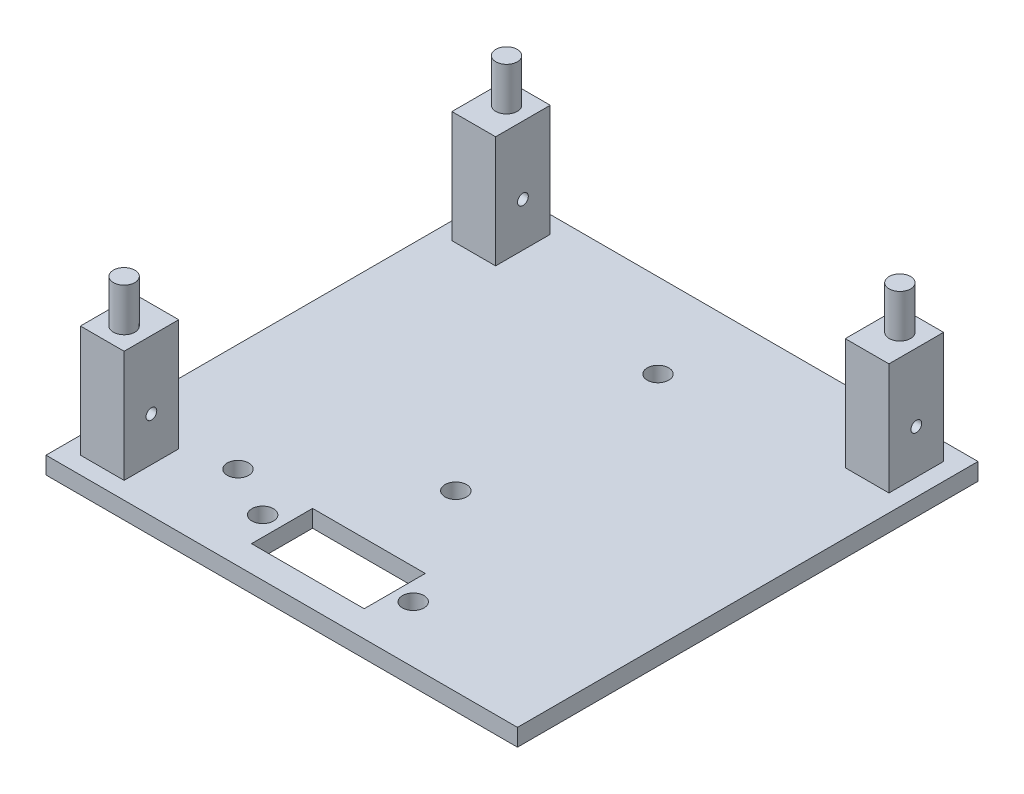
from build123d import *

# Parameters (mm, degrees)
SKETCH2_W           = 54.8
SKETCH2_H           = 53.53
BOSS_EXTRUDE1_DEPTH = 2
SKETCH3_W           = 5.08
SKETCH3_H           = 6.35
BOSS_EXTRUDE2_DEPTH = 13
SKETCH6_R           = 1.25
BOSS_EXTRUDE3_DEPTH = 5
CUT_EXTRUDE1_REACH  = 22
SKETCH7_W           = 13.1
SKETCH7_H           = 7.1
CUT_EXTRUDE2_REACH  = 22
SKETCH8_R           = 1.25
CUT_EXTRUDE4_REACH  = 54.8
SKETCH9_R           = 0.625
CUT_EXTRUDE5_REACH  = 54.8
SKETCH10_R          = 0.625
CUT_EXTRUDE6_REACH  = 54.8
SKETCH11_R          = 0.625
CUT_EXTRUDE7_REACH  = 4
SKETCH12_R          = 1.25
CUT_EXTRUDE8_REACH  = 4
SKETCH13_R          = 1.25


with BuildPart() as part:
    # Sketch2 → Boss-Extrude1 (new body)
    with BuildSketch(Plane(origin=(0, 0, 0), x_dir=(1, 0, 0), z_dir=(0, 1, 0))):
        Rectangle(SKETCH2_W, SKETCH2_H)
    extrude(amount=BOSS_EXTRUDE1_DEPTH)

    # Sketch3 → Boss-Extrude2 (add)
    with BuildSketch(Plane(origin=(0, 2, 0), x_dir=(1, 0, 0), z_dir=(0, 1, 0))):
        with Locations((-22.86, 21.59)):
            Rectangle(SKETCH3_W, SKETCH3_H)
        with Locations((22.86, 21.59)):
            Rectangle(SKETCH3_W, SKETCH3_H)
        with Locations((-22.86, -21.59)):
            Rectangle(SKETCH3_W, SKETCH3_H)
    extrude(amount=BOSS_EXTRUDE2_DEPTH)

    # Sketch6 → Boss-Extrude3 (add)
    with BuildSketch(Plane(origin=(0, 15, 0), x_dir=(1, 0, 0), z_dir=(0, 1, 0))):
        with Locations((-22.86, 22.225)):
            Circle(SKETCH6_R)
        with Locations((22.86, 22.225)):
            Circle(SKETCH6_R)
        with Locations((-22.86, -22.225)):
            Circle(SKETCH6_R)
    extrude(amount=BOSS_EXTRUDE3_DEPTH)

    # Sketch7 → Cut-Extrude1 (cut, up to next)
    with BuildSketch(Plane(origin=(0, 0, 0), x_dir=(-1, 0, 0), z_dir=(0, -1, 0)), mode=Mode.PRIVATE) as cut_extrude1_sk1:
        with Locations((0, -20.180596319)):
            Rectangle(SKETCH7_W, SKETCH7_H)
    cut_extrude1_tool1 = extrude(cut_extrude1_sk1.sketch, amount=-CUT_EXTRUDE1_REACH, mode=Mode.PRIVATE) & part.part
    add(cut_extrude1_tool1.solids().sort_by_distance((0, 0, 20.180596))[0], mode=Mode.SUBTRACT)

    # Sketch8 → Cut-Extrude2 (cut, up to next)
    with BuildSketch(Plane.XZ, mode=Mode.PRIVATE) as cut_extrude2_sk1:
        with Locations((0, 6.530805807)):
            Circle(SKETCH8_R)
    cut_extrude2_tool1 = extrude(cut_extrude2_sk1.sketch, amount=-CUT_EXTRUDE2_REACH, mode=Mode.PRIVATE) & part.part
    add(cut_extrude2_tool1.solids().sort_by_distance((0, 0, 6.530806))[0], mode=Mode.SUBTRACT)
    # Sketch8 → Cut-Extrude2 (cut, up to next)
    with BuildSketch(Plane.XZ, mode=Mode.PRIVATE) as cut_extrude2_sk2:
        with Locations((0, -16.969194193)):
            Circle(SKETCH8_R)
    cut_extrude2_tool2 = extrude(cut_extrude2_sk2.sketch, amount=-CUT_EXTRUDE2_REACH, mode=Mode.PRIVATE) & part.part
    add(cut_extrude2_tool2.solids().sort_by_distance((0, 0, -16.969194))[0], mode=Mode.SUBTRACT)

    # Sketch9 → Cut-Extrude4 (cut, up to next)
    with BuildSketch(Plane.ZY.offset(25.4), mode=Mode.PRIVATE) as cut_extrude4_sk1:
        with Locations((-21.59, 7.11470595)):
            Circle(SKETCH9_R)
    cut_extrude4_tool1 = extrude(cut_extrude4_sk1.sketch, amount=-CUT_EXTRUDE4_REACH, mode=Mode.PRIVATE) & part.part
    add(cut_extrude4_tool1.solids().sort_by_distance((-25.4, 7.114706, -21.59))[0], mode=Mode.SUBTRACT)

    # Sketch10 → Cut-Extrude5 (cut, up to next)
    with BuildSketch(Plane(origin=(25.4, 0, 0), x_dir=(0, 0, -1), z_dir=(1, 0, 0)), mode=Mode.PRIVATE) as cut_extrude5_sk1:
        with Locations((21.595, 7.11)):
            Circle(SKETCH10_R)
    cut_extrude5_tool1 = extrude(cut_extrude5_sk1.sketch, amount=-CUT_EXTRUDE5_REACH, mode=Mode.PRIVATE) & part.part
    add(cut_extrude5_tool1.solids().sort_by_distance((25.4, 7.11, -21.595))[0], mode=Mode.SUBTRACT)

    # Sketch11 → Cut-Extrude6 (cut, up to next)
    with BuildSketch(Plane.ZY.offset(25.4), mode=Mode.PRIVATE) as cut_extrude6_sk1:
        with Locations((21.595, 7.11)):
            Circle(SKETCH11_R)
    cut_extrude6_tool1 = extrude(cut_extrude6_sk1.sketch, amount=-CUT_EXTRUDE6_REACH, mode=Mode.PRIVATE) & part.part
    add(cut_extrude6_tool1.solids().sort_by_distance((-25.4, 7.11, 21.595))[0], mode=Mode.SUBTRACT)

    # Sketch12 → Cut-Extrude7 (cut, up to next)
    with BuildSketch(Plane(origin=(0, 2, 0), x_dir=(1, 0, 0), z_dir=(0, 1, 0)), mode=Mode.PRIVATE) as cut_extrude7_sk1:
        with Locations((-14.835465402, -17.017151491)):
            Circle(SKETCH12_R)
    cut_extrude7_tool1 = extrude(cut_extrude7_sk1.sketch, amount=-CUT_EXTRUDE7_REACH, mode=Mode.PRIVATE) & part.part
    add(cut_extrude7_tool1.solids().sort_by_distance((-14.835465, 2, 17.017151))[0], mode=Mode.SUBTRACT)

    # Sketch13 → Cut-Extrude8 (cut, up to next)
    with BuildSketch(Plane(origin=(0, 2, 0), x_dir=(1, 0, 0), z_dir=(0, 1, 0)), mode=Mode.PRIVATE) as cut_extrude8_sk1:
        with Locations((-8.8, -20.180596319)):
            Circle(SKETCH13_R)
    cut_extrude8_tool1 = extrude(cut_extrude8_sk1.sketch, amount=-CUT_EXTRUDE8_REACH, mode=Mode.PRIVATE) & part.part
    add(cut_extrude8_tool1.solids().sort_by_distance((-8.8, 2, 20.180596))[0], mode=Mode.SUBTRACT)
    # Sketch13 → Cut-Extrude8 (cut, up to next)
    with BuildSketch(Plane(origin=(0, 2, 0), x_dir=(1, 0, 0), z_dir=(0, 1, 0)), mode=Mode.PRIVATE) as cut_extrude8_sk2:
        with Locations((8.7, -20.180596319)):
            Circle(SKETCH13_R)
    cut_extrude8_tool2 = extrude(cut_extrude8_sk2.sketch, amount=-CUT_EXTRUDE8_REACH, mode=Mode.PRIVATE) & part.part
    add(cut_extrude8_tool2.solids().sort_by_distance((8.7, 2, 20.180596))[0], mode=Mode.SUBTRACT)


solid = part.part
